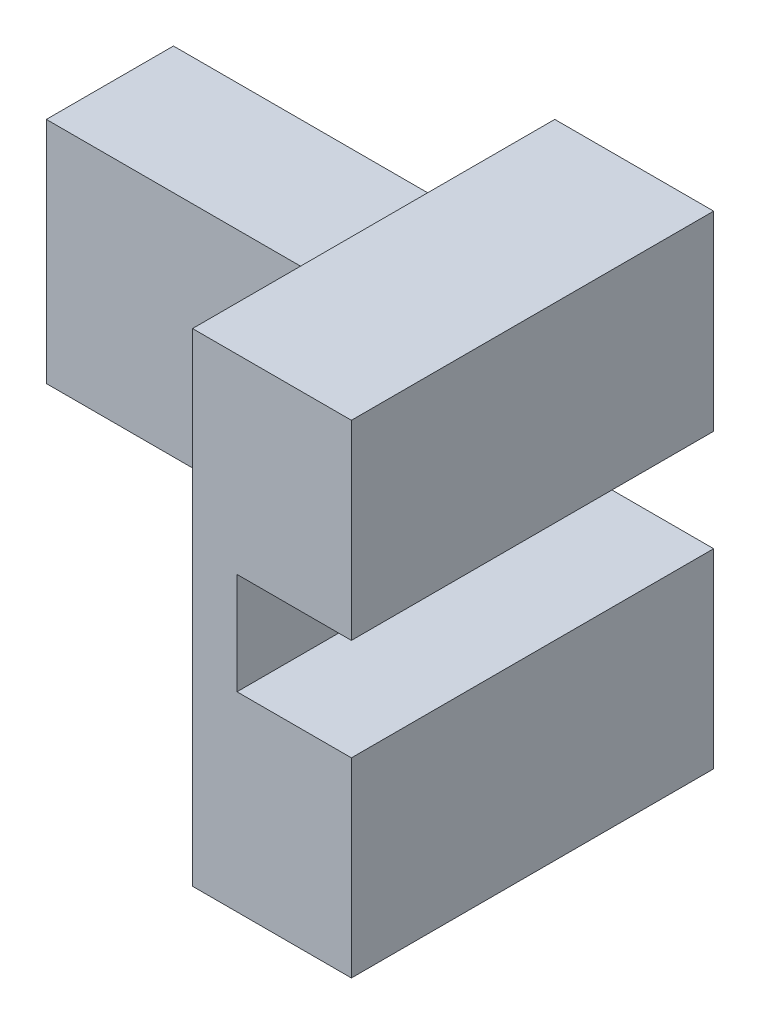
from build123d import *

# Parameters (mm, degrees)
BOSS_EXTRUDE1_DEPTH = 2
BOSS_EXTRUDE2_DEPTH = 3.7


with BuildPart() as part:
    # Sketch1 → Boss-Extrude1 (new body)
    with BuildSketch(Plane.XY):
        Polygon((-14.259347555, 17.248938456), (-14.259347555, 15.648938456), (-12.459347555, 15.648938456), (-12.459347555, 12.648938456), (-14.959347555, 12.648938456), (-14.959347555, 14.648938456), (-20.959347555, 14.648938456), (-20.959347555, 18.248938456), (-14.959347555, 18.248938456), (-14.959347555, 20.248938456), (-12.459347555, 20.248938456), (-12.459347555, 17.248938456), align=None)
    extrude(amount=BOSS_EXTRUDE1_DEPTH)

    # Sketch2 → Boss-Extrude2 (add)
    with BuildSketch(Plane.XY.offset(2)):
        Polygon((-14.959347555, 20.248938456), (-12.459347555, 20.248938456), (-12.459347555, 17.248938456), (-14.259347555, 17.248938456), (-14.259347555, 15.648938456), (-12.459347555, 15.648938456), (-12.459347555, 12.648938456), (-14.959347555, 12.648938456), align=None)
    extrude(amount=BOSS_EXTRUDE2_DEPTH)


solid = part.part
